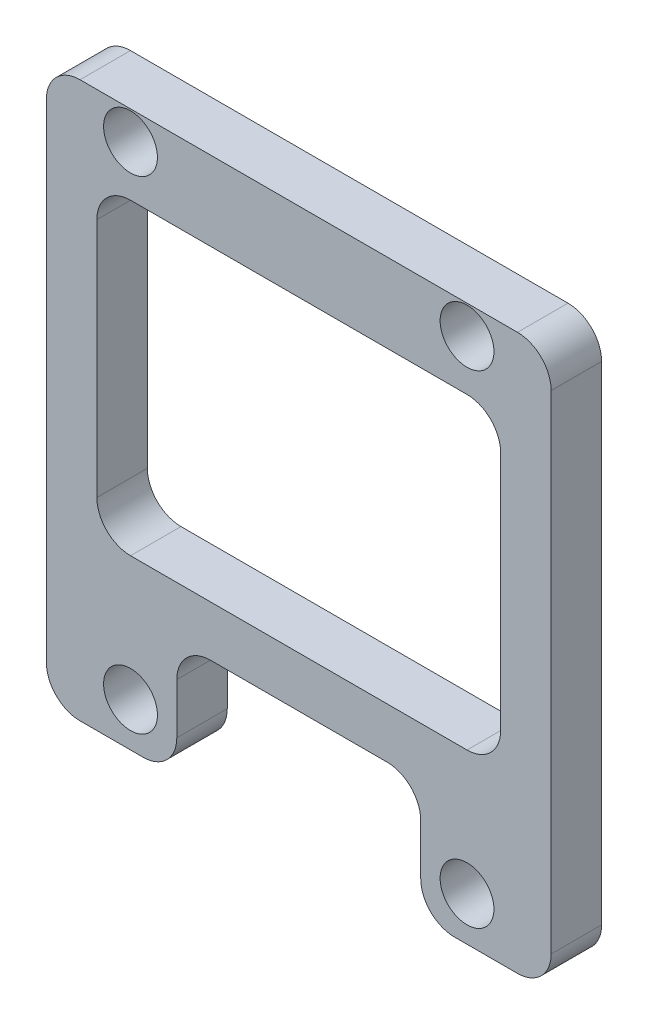
from build123d import *

# Parameters (mm, degrees)
SKETCH_1_W          = 30
SKETCH_1_H          = 33
SKETCH_1_R          = 1.6
EXTRUDE_1_DEPTH     = 3
SKETCH_2_W          = 14.5
SKETCH_2_H          = 7
SKETCH_2_W_2        = 24
SKETCH_2_H_2        = 18.3
CUT_EXTRUDE_1_DEPTH = 4
FILLET_1_R          = 2
FILLET_2_R          = 2


with BuildPart() as part:
    # 草图1 → 凸台-拉伸1 (new body)
    with BuildSketch(Plane.XY):
        with Locations((15, 16.5)):
            Rectangle(SKETCH_1_W, SKETCH_1_H)
        with Locations((5, 31.3)):
            Circle(SKETCH_1_R, mode=Mode.SUBTRACT)
        with Locations((25, 31.3)):
            Circle(SKETCH_1_R, mode=Mode.SUBTRACT)
        with Locations((25, 2.6)):
            Circle(SKETCH_1_R, mode=Mode.SUBTRACT)
        with Locations((5, 2.6)):
            Circle(SKETCH_1_R, mode=Mode.SUBTRACT)
    extrude(amount=EXTRUDE_1_DEPTH)

    # 草图2 → 切除-拉伸1 (cut, through all)
    with BuildSketch(Plane.XY.offset(3)):
        with Locations((15, 3.5)):
            Rectangle(SKETCH_2_W, SKETCH_2_H)
        with Locations((15, 19.15)):
            Rectangle(SKETCH_2_W_2, SKETCH_2_H_2)
    extrude(amount=-CUT_EXTRUDE_1_DEPTH, mode=Mode.SUBTRACT)

    # 圆角1
    fillet_1_edges = [part.edges().sort_by_distance(p)[0] for p in [
        (0, 33, 1.5),
        (30, 33, 1.5),
        (30, 0, 1.5),
        (0, 0, 1.5),
    ]]
    fillet(fillet_1_edges, radius=FILLET_1_R)

    # 圆角2
    fillet_2_edges = [part.edges().sort_by_distance(p)[0] for p in [
        (7.75, 0, 1.5),
        (7.75, 7, 1.5),
        (22.25, 7, 1.5),
        (22.25, 0, 1.5),
        (3, 10, 1.5),
        (3, 28.3, 1.5),
        (27, 28.3, 1.5),
        (27, 10, 1.5),
    ]]
    fillet(fillet_2_edges, radius=FILLET_2_R)


solid = part.part
